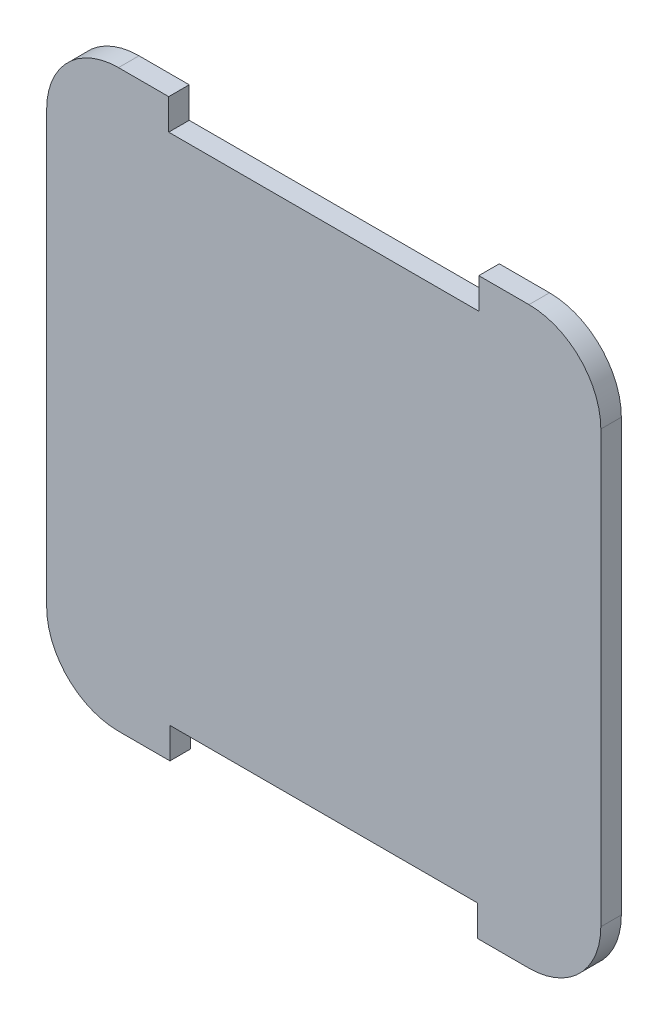
from build123d import *

# Parameters (mm, degrees)
BOSS_EXTRUDE1_DEPTH = 1
CUT_EXTRUDE1_REACH  = 3
SKETCH2_W           = 15.10750805
SKETCH2_H           = 1.5


with BuildPart() as part:
    # Sketch1 → Boss-Extrude1 (new body)
    with BuildSketch(Plane.XY):
        with BuildLine():
            Line((-13.5, 10.5), (-13.5, -10.5))
            ThreePointArc((-13.5, -10.5), (-12.474873734, -12.974873734), (-10, -14))
            Line((-10, -14), (10, -14))
            ThreePointArc((10, -14), (12.474873734, -12.974873734), (13.5, -10.5))
            Line((13.5, -10.5), (13.5, 10.5))
            ThreePointArc((13.5, 10.5), (12.474873734, 12.974873734), (10, 14))
            Line((10, 14), (-10, 14))
            ThreePointArc((-10, 14), (-12.474873734, 12.974873734), (-13.5, 10.5))
        make_face()
    extrude(amount=BOSS_EXTRUDE1_DEPTH)

    # Sketch2 → Cut-Extrude1 (cut, up to next)
    with BuildSketch(Plane.XY.offset(1), mode=Mode.PRIVATE) as cut_extrude1_sk1:
        with Locations((0, 13.25)):
            Rectangle(SKETCH2_W, SKETCH2_H)
    cut_extrude1_tool1 = extrude(cut_extrude1_sk1.sketch, amount=-CUT_EXTRUDE1_REACH, mode=Mode.PRIVATE) & part.part
    add(cut_extrude1_tool1.solids().sort_by_distance((0, 13.25, 1))[0], mode=Mode.SUBTRACT)
    # Sketch2 → Cut-Extrude1 (cut, up to next)
    with BuildSketch(Plane.XY.offset(1), mode=Mode.PRIVATE) as cut_extrude1_sk2:
        Polygon((-7.493203699, -14), (7.493203699, -14), (7.496447466, -12.5), (-7.496447466, -12.5), align=None)
    cut_extrude1_tool2 = extrude(cut_extrude1_sk2.sketch, amount=-CUT_EXTRUDE1_REACH, mode=Mode.PRIVATE) & part.part
    add(cut_extrude1_tool2.solids().sort_by_distance((0, -13.249946, 1))[0], mode=Mode.SUBTRACT)


solid = part.part
